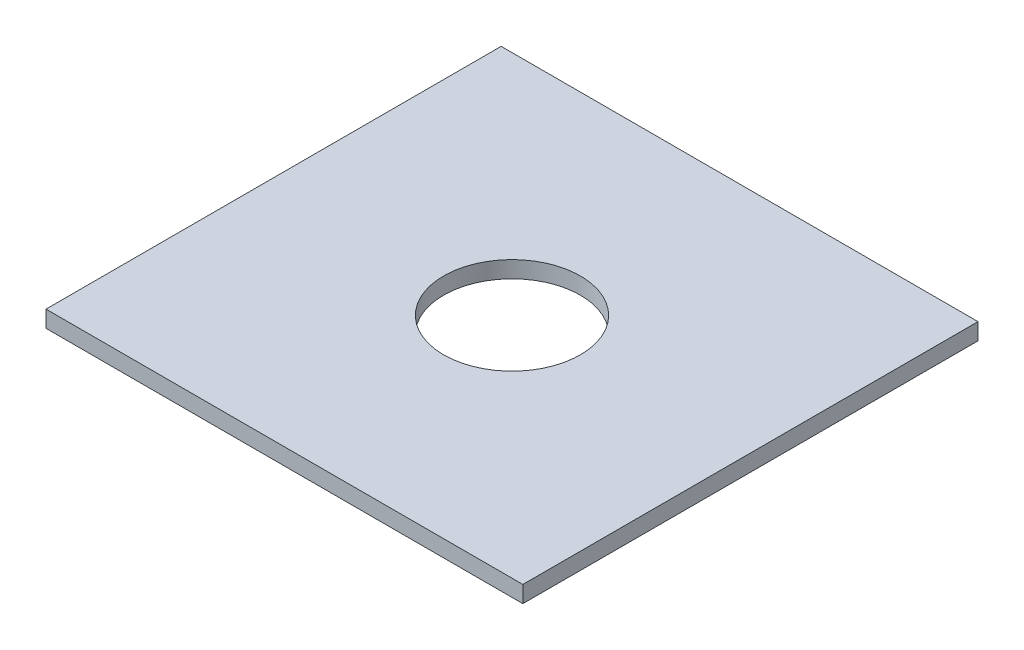
from build123d import *

# Parameters (mm, degrees)
CROQUIS1_W              = 286
CROQUIS1_H              = 273
CROQUIS1_R              = 41
SALIENTE_EXTRUIR1_DEPTH = 10


with BuildPart() as part:
    # Croquis1 → Saliente-Extruir1 (new body)
    with BuildSketch(Plane(origin=(0, 0, 0), x_dir=(1, 0, 0), z_dir=(0, 1, 0))):
        Rectangle(CROQUIS1_W, CROQUIS1_H)
        Circle(CROQUIS1_R, mode=Mode.SUBTRACT)
    extrude(amount=SALIENTE_EXTRUIR1_DEPTH)


solid = part.part
